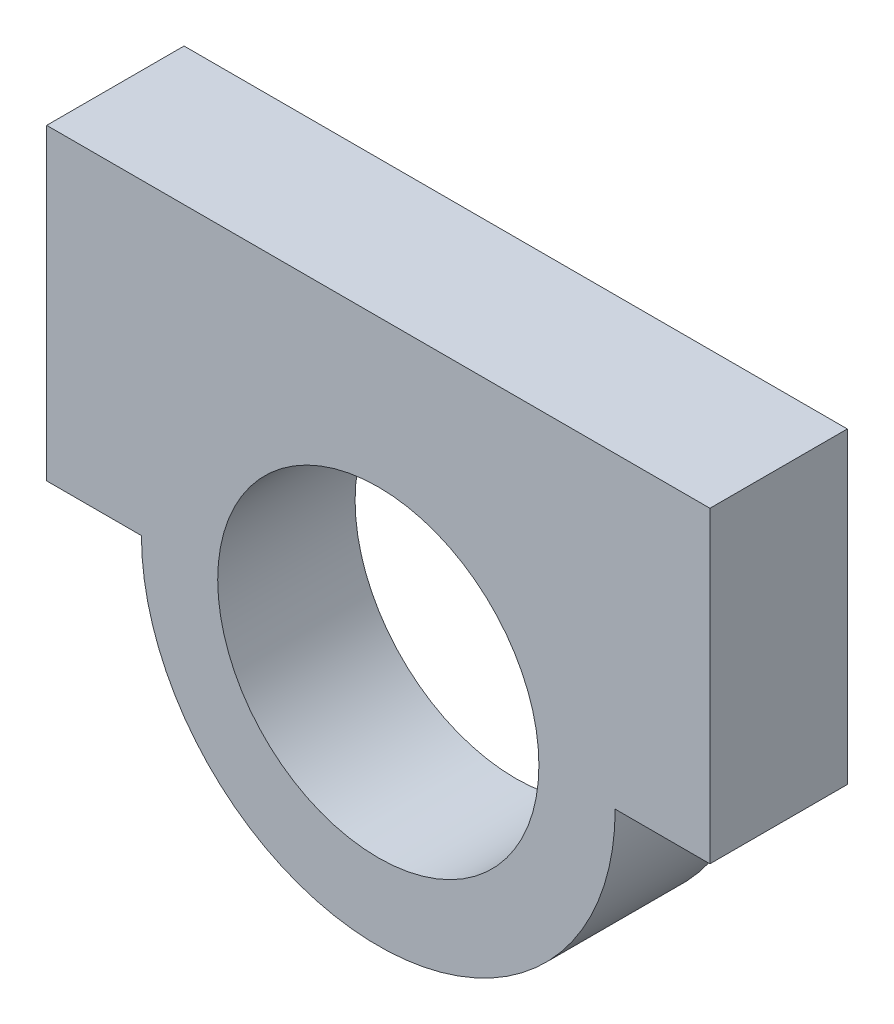
from build123d import *

# Parameters (mm, degrees)
SKETCH_1_R      = 50
SKETCH_1_R_2    = 33.9
EXTRUDE_1_DEPTH = 29


with BuildPart() as part:
    # Эскиз1 → Бобышка-Вытянуть1 (new body)
    with BuildSketch(Plane.XY):
        Circle(SKETCH_1_R)
        Circle(SKETCH_1_R_2, mode=Mode.SUBTRACT)
        with BuildLine():
            Line((70, 65), (-70, 65))
            Line((-70, 65), (-70, 0))
            Line((-70, 0), (-50, 0))
            ThreePointArc((-50, 0), (0, 50), (50, 0))
            Line((50, 0), (70, 0))
            Line((70, 0), (70, 65))
        make_face()
    extrude(amount=EXTRUDE_1_DEPTH)


solid = part.part
